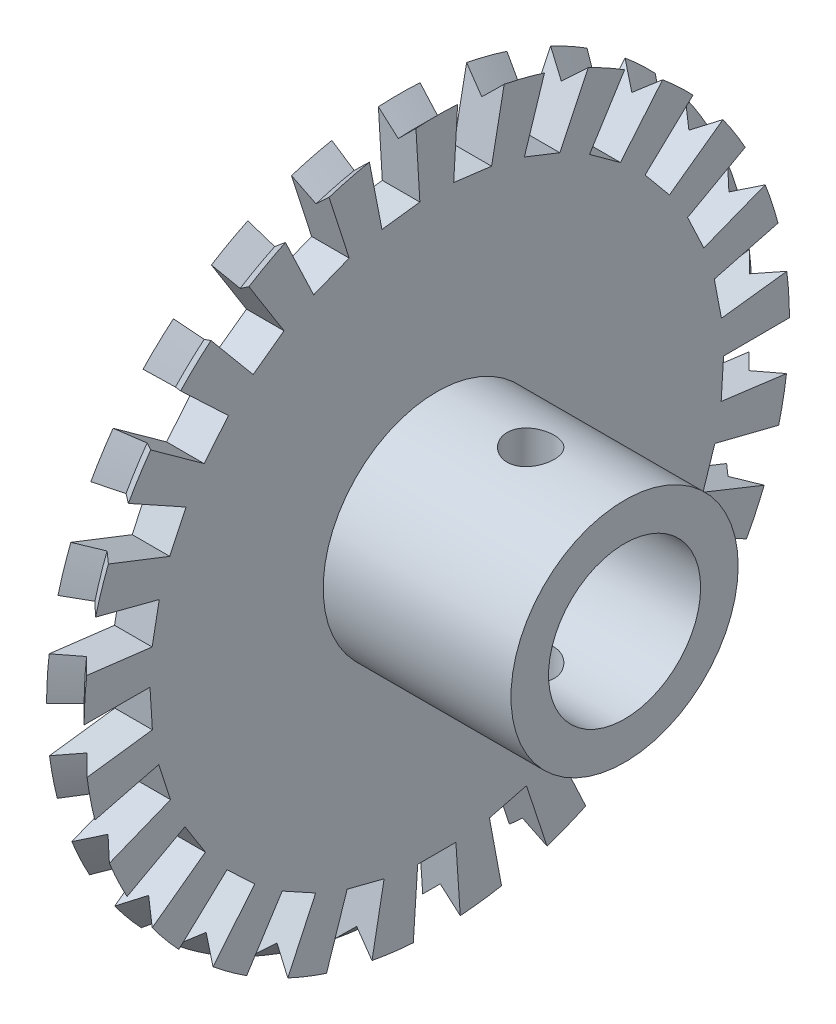
from build123d import *

# Parameters (mm, degrees)
SKETCH2_R           = 18.78
SKETCH2_R_2         = 4.05
BOSS_EXTRUDE1_DEPTH = 1
SKETCH9_R           = 6.05
SKETCH9_R_2         = 4.05
BOSS_EXTRUDE2_DEPTH = 10
SKETCH10_R          = 1.25
CUT_EXTRUDE1_DEPTH  = 10
CUT_EXTRUDE3_DEPTH  = 10
CIRPATTERN1_COUNT   = 25


with BuildPart() as part:
    # Sketch2 → Boss-Extrude1 (new, symmetric)
    with BuildSketch(Plane(origin=(0, 0, 0), x_dir=(0, 0, -1), z_dir=(1, 0, 0))):
        Circle(SKETCH2_R)
        Circle(SKETCH2_R_2, mode=Mode.SUBTRACT)
    extrude(amount=BOSS_EXTRUDE1_DEPTH, both=True)

    # Sketch9 → Boss-Extrude2 (add)
    with BuildSketch(Plane(origin=(1, 0, 0), x_dir=(0, 0, -1), z_dir=(1, 0, 0))):
        Circle(SKETCH9_R)
        Circle(SKETCH9_R_2, mode=Mode.SUBTRACT)
    extrude(amount=BOSS_EXTRUDE2_DEPTH)

    # Sketch5 → Cut-Revolve1 (revolve, cut)
    with BuildSketch(Plane(origin=(0, 0, 0), x_dir=(1, 0, 0), z_dir=(0, 1, 0)), mode=Mode.PRIVATE) as cut_revolve1_sk:
        Polygon((-1, -18.78), (0, -17.78), (1, -18.78), align=None)
    revolve(cut_revolve1_sk.sketch.rotate(Axis((11, 0, 0), (-1, 0, 0)), 180), axis=Axis((11, 0, 0), (-1, 0, 0)), mode=Mode.SUBTRACT)

    # Sketch10 → Cut-Extrude1 (cut, symmetric)
    with BuildSketch(Plane(origin=(0, 0, 0), x_dir=(1, 0, 0), z_dir=(0, 1, 0))):
        with Locations(Location((6, 0, 0), (0, 0, 270))):
            Circle(SKETCH10_R)
    extrude(amount=CUT_EXTRUDE1_DEPTH, both=True, mode=Mode.SUBTRACT)

    # Sketch12 → Cut-Extrude3 (cut, symmetric)
    with BuildSketch(Plane(origin=(1, 0, 0), x_dir=(0, 0, -1), z_dir=(1, 0, 0))):
        with BuildLine():
            ThreePointArc((-1.25, -18.738353716), (0, -18.78), (1.25, -18.738353716))
            Line((1.25, -18.738353716), (1.016521645, -15.238353716))
            Line((1.016521645, -15.238353716), (-1.016521645, -15.238353716))
            Line((-1.016521645, -15.238353716), (-1.25, -18.738353716))
        make_face()
    cut_extrude3 = extrude(amount=CUT_EXTRUDE3_DEPTH, both=True, mode=Mode.SUBTRACT)

    # CirPattern1: Cut-Extrude3 ×25 about axis
    cirpattern1_axis = Axis((0, 0, 0), (1, 0, 0))
    for i in range(1, CIRPATTERN1_COUNT):
        add(cut_extrude3.rotate(cirpattern1_axis, i * 360 / CIRPATTERN1_COUNT), mode=Mode.SUBTRACT)


solid = part.part
